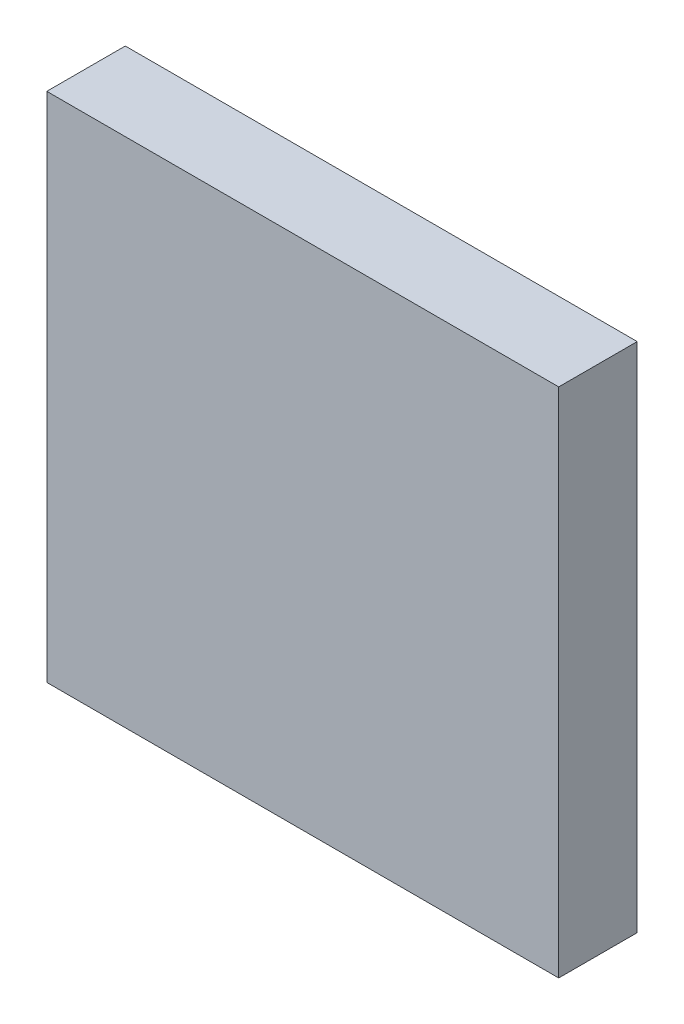
from build123d import *

# Parameters (mm, degrees)
SKETCH_1_W      = 15
SKETCH_1_H      = 15
EXTRUDE_1_DEPTH = 2.3


with BuildPart() as part:
    # 草图1 → 凸台-拉伸1 (new body)
    with BuildSketch(Plane.XY):
        with Locations((54.307491971, 30.781620917)):
            Rectangle(SKETCH_1_W, SKETCH_1_H)
    extrude(amount=EXTRUDE_1_DEPTH)


solid = part.part
